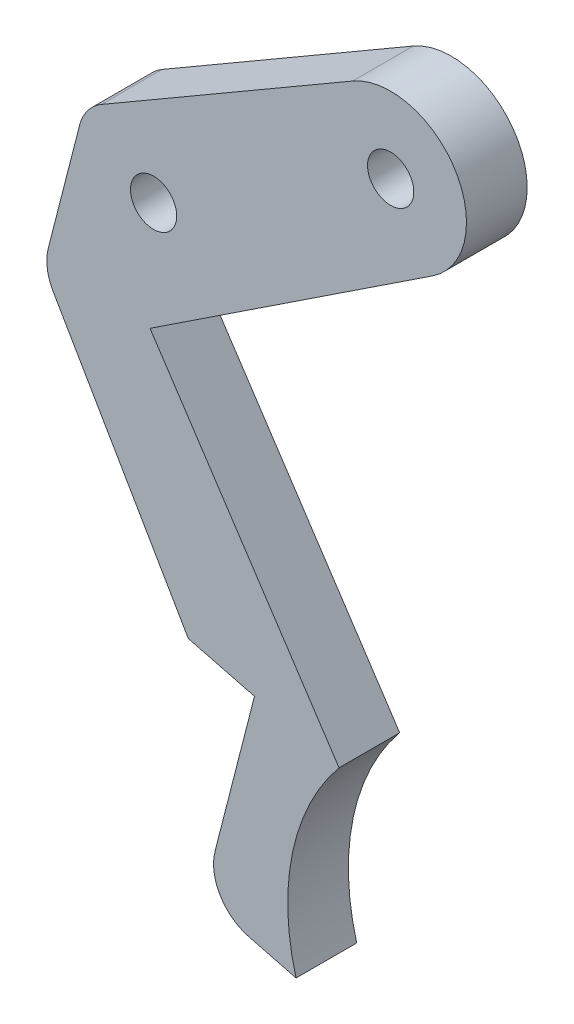
from build123d import *

# Parameters (mm, degrees)
SALIENTE_EXTRUIR1_DEPTH    = 10
CROQUIS4_R                 = 3.81
CORTAR_EXTRUIR1_DEPTH      = 61.468
CORTAR_EXTRUIR1_DEPTH_BACK = 64.008


with BuildPart() as part:
    # Croquis2 → Saliente-Extruir1 (new body)
    with BuildSketch(Plane.XY):
        with BuildLine():
            Line((-51.279919423, -17.994736431), (-56.441706153, -38.125704677))
            ThreePointArc((-56.441706153, -38.125704677), (-56.611211976, -41.10511644), (-55.639925501, -43.92685868))
            Line((-55.639925501, -43.92685868), (-33.368069091, -82.317782173))
            Line((-33.368069091, -82.317782173), (-22.449197371, -85.11749287))
            Line((-22.449197371, -85.11749287), (-28.956418222, -110.495654186))
            ThreePointArc((-28.956418222, -110.495654186), (-28.120578041, -116.354933217), (-23.386413845, -119.907040892))
            Line((-23.386413845, -119.907040892), (-15.596975427, -121.904332794))
            ThreePointArc((-15.596975427, -121.904332794), (-16.177038504, -104.258895505), (-8.511603611, -88.354838218))
            Line((-8.511603611, -88.354838218), (-39.670979585, -41.190293696))
            Line((-39.670979585, -41.190293696), (6.890267505, -10.429487701))
            ThreePointArc((6.890267505, -10.429487701), (10.624002053, 6.586393579), (-6.277032388, 10.809665323))
            Line((-6.277032388, 10.809665323), (-47.67245646, -13.22812029))
            ThreePointArc((-47.67245646, -13.22812029), (-49.955399161, -15.248752476), (-51.279919423, -17.994736431))
        make_face()
    extrude(amount=SALIENTE_EXTRUIR1_DEPTH)

    # Croquis4 → Cortar-Extruir1 (cut, two sides)
    with BuildSketch(Plane.XY) as cortar_extruir1_sk:
        Circle(CROQUIS4_R)
        with Locations((-39.080143485, -22.972272641)):
            Circle(CROQUIS4_R)
    extrude(amount=CORTAR_EXTRUIR1_DEPTH, mode=Mode.SUBTRACT)
    extrude(cortar_extruir1_sk.sketch, amount=-CORTAR_EXTRUIR1_DEPTH_BACK, mode=Mode.SUBTRACT)


solid = part.part
